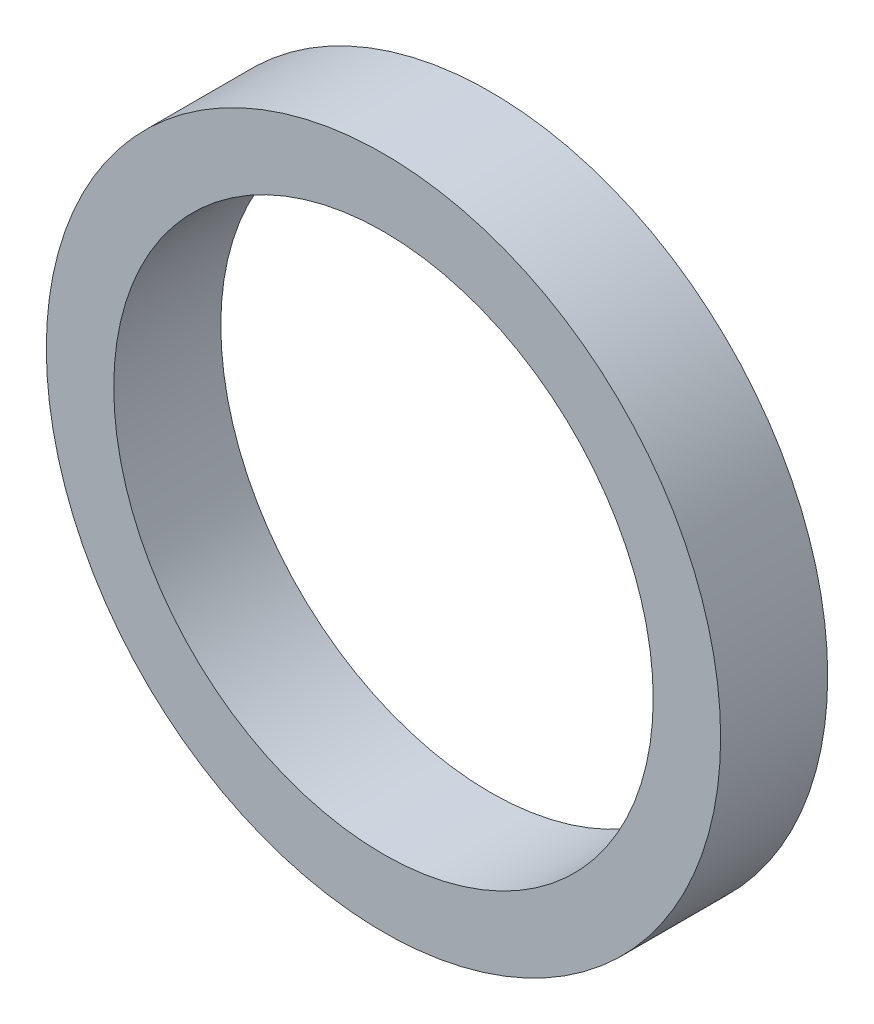
from build123d import *

# Parameters (mm, degrees)
SKETCH1_R           = 5
SKETCH1_R_2         = 4
BOSS_EXTRUDE1_DEPTH = 1.5875


with BuildPart() as part:
    # Sketch1 → Boss-Extrude1 (new body)
    with BuildSketch(Plane.XY):
        Circle(SKETCH1_R)
        Circle(SKETCH1_R_2, mode=Mode.SUBTRACT)
    extrude(amount=BOSS_EXTRUDE1_DEPTH)


solid = part.part
